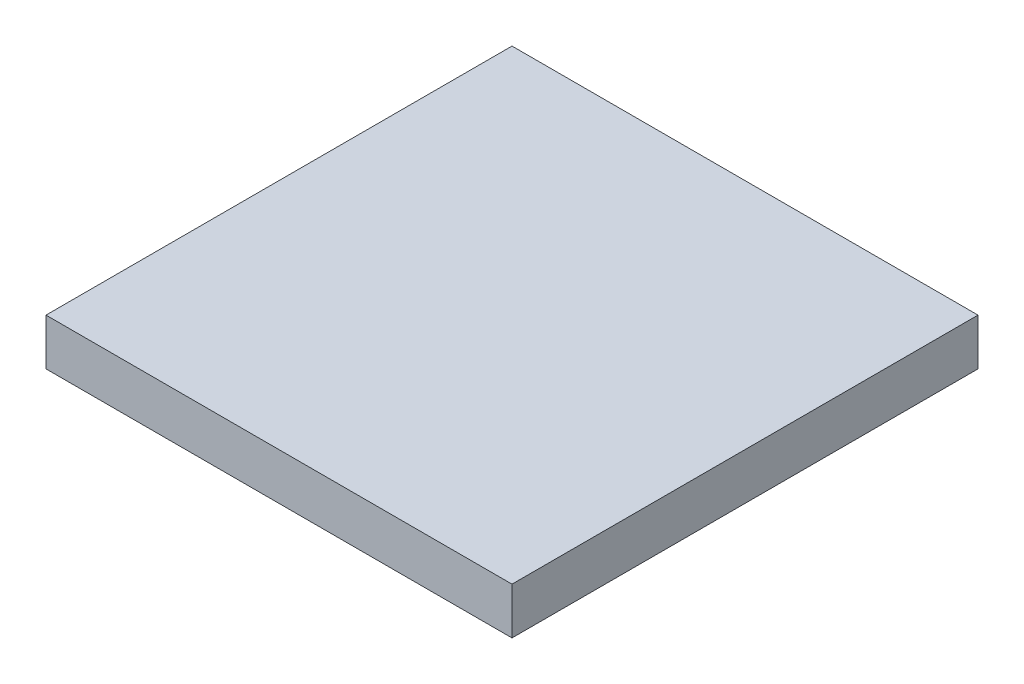
from build123d import *

# Parameters (mm, degrees)
ESQUISSE1_W        = 300
ESQUISSE1_H        = 300
BOSS_EXTRU_1_DEPTH = 30


with BuildPart() as part:
    # Esquisse1 → Boss.-Extru.1 (new body)
    with BuildSketch(Plane(origin=(0, 0, 0), x_dir=(1, 0, 0), z_dir=(0, 1, 0))):
        Rectangle(ESQUISSE1_W, ESQUISSE1_H)
    extrude(amount=BOSS_EXTRU_1_DEPTH)


solid = part.part
